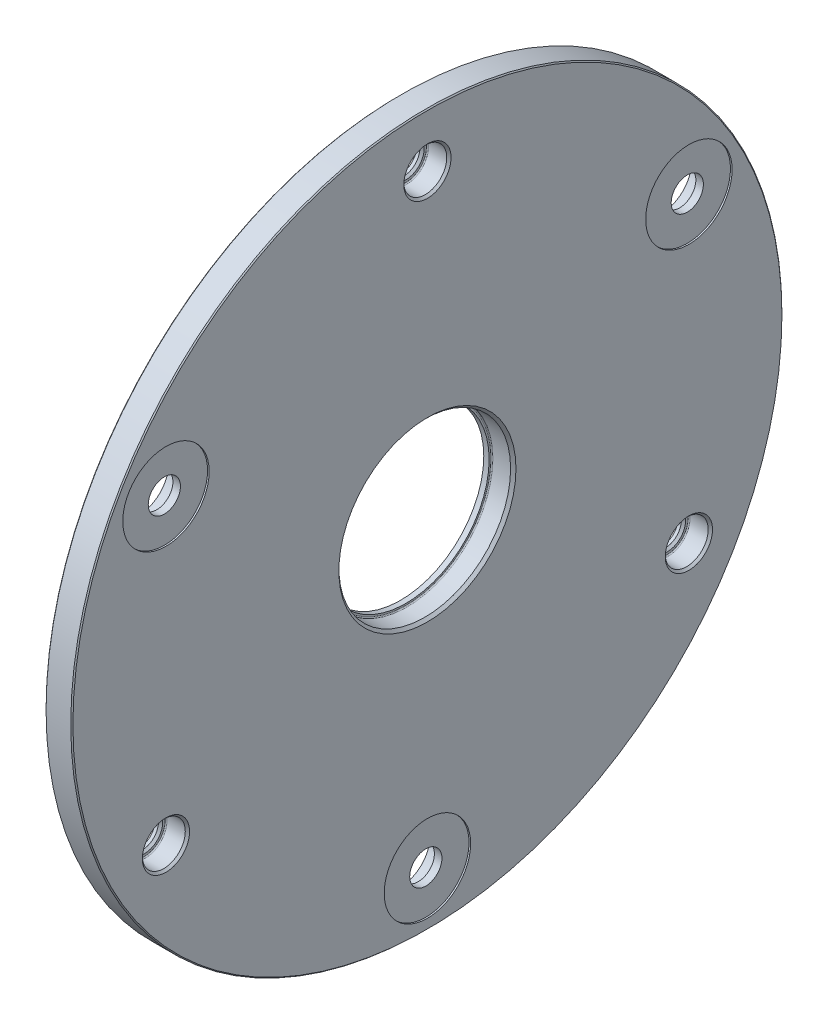
from build123d import *

# Parameters (mm, degrees)
SKETCH2_R                       = 66.25
SKETCH2_R_2                     = 16
BOSS_EXTRUDE1_DEPTH             = 5
SKETCH4_R                       = 3
CUT_EXTRUDE1_DEPTH              = 5
SKETCH4_3_R                     = 4
SKETCH4_3_R_2                   = 3
CUT_EXTRUDE2_DEPTH              = 4
CHAMFER1_SIZE                   = 0.4
FILLET3_R                       = 0.2
SKETCH5_R                       = 8.05
CUT_EXTRUDE3_DEPTH              = 0.3
CBORE_FOR_M6_SBHCS1_D           = 6
CBORE_FOR_M6_SBHCS1_CBORE_D     = 11
CBORE_FOR_M6_SBHCS1_CBORE_DEPTH = 3.3
CIRPATTERN1_COUNT               = 3
CHAMFER1_OF_CIRPATTERN1_SIZE    = 0.4
FILLET3_OF_CIRPATTERN1_R        = 0.2
BOSS_EXTRUDE2_START             = -5
SKETCH8_R                       = 16
SKETCH8_R_2                     = 15.5
BOSS_EXTRUDE2_DEPTH             = 1
FILLET2_R                       = 0.2
CHAMFER2_SIZE                   = 0.5
CHAMFER3_SIZE                   = 0.2


with BuildPart() as part:
    # Sketch2 → Boss-Extrude1 (new body)
    with BuildSketch(Plane(origin=(0, 0, 0), x_dir=(0, 0, -1), z_dir=(1, 0, 0))):
        Circle(SKETCH2_R)
        Circle(SKETCH2_R_2, mode=Mode.SUBTRACT)
    extrude(amount=-BOSS_EXTRUDE1_DEPTH)

    # Sketch4 → Cut-Extrude1 (cut)
    with BuildSketch(Plane(origin=(0, 0, 0), x_dir=(0, 0, -1), z_dir=(1, 0, 0))):
        with Locations((0, 56.25)):
            Circle(SKETCH4_R)
    cut_extrude1 = extrude(amount=-CUT_EXTRUDE1_DEPTH, mode=Mode.SUBTRACT)

    # Sketch4_3 → Cut-Extrude2 (cut)
    with BuildSketch(Plane(origin=(0, 0, 0), x_dir=(0, 0, -1), z_dir=(1, 0, 0))):
        with Locations((0, 56.25)):
            Circle(SKETCH4_3_R)
        with Locations((0, 56.25)):
            Circle(SKETCH4_3_R_2, mode=Mode.SUBTRACT)
    cut_extrude2 = extrude(amount=-CUT_EXTRUDE2_DEPTH, mode=Mode.SUBTRACT)

    # Chamfer1
    chamfer1_edges = [part.edges().sort_by_distance(p)[0] for p in [
        (0, 56.25, 4),
        (-4, 56.25, 3),
    ]]
    chamfer(chamfer1_edges, length=CHAMFER1_SIZE)

    # Fillet3
    fillet3_edges = [part.edges().sort_by_distance(p)[0] for p in [
        (-4, 56.25, 4),
    ]]
    fillet(fillet3_edges, radius=FILLET3_R)

    # Sketch5 → Cut-Extrude3 (cut)
    with BuildSketch(Plane(origin=(0, 0, 0), x_dir=(0, 0, -1), z_dir=(1, 0, 0))):
        with Locations((48.713928963, 28.125)):
            Circle(SKETCH5_R)
    cut_extrude3 = extrude(amount=-CUT_EXTRUDE3_DEPTH, mode=Mode.SUBTRACT)

    # CBORE for M6 SBHCS1 (through all)
    with Locations(Plane.ZY.offset(5)):
        with Locations((-48.713928963, 28.125)):
            cbore_for_m6_sbhcs1 = CounterBoreHole(CBORE_FOR_M6_SBHCS1_D / 2, CBORE_FOR_M6_SBHCS1_CBORE_D / 2, CBORE_FOR_M6_SBHCS1_CBORE_DEPTH)

    # CirPattern1: Cut-Extrude1, Cut-Extrude2, Cut-Extrude3, CBORE for M6 SBHCS1 ×3 about axis
    cirpattern1_axis = Axis((0, 0, 0), (1, 0, 0))
    for i in range(1, CIRPATTERN1_COUNT):
        add(cut_extrude1.rotate(cirpattern1_axis, i * 360 / CIRPATTERN1_COUNT), mode=Mode.SUBTRACT)
        add(cut_extrude2.rotate(cirpattern1_axis, i * 360 / CIRPATTERN1_COUNT), mode=Mode.SUBTRACT)
        add(cut_extrude3.rotate(cirpattern1_axis, i * 360 / CIRPATTERN1_COUNT), mode=Mode.SUBTRACT)
        add(cbore_for_m6_sbhcs1.rotate(cirpattern1_axis, i * 360 / CIRPATTERN1_COUNT), mode=Mode.SUBTRACT)

    # Chamfer1 of CirPattern1
    chamfer1_of_cirpattern1_edges = [part.edges().sort_by_distance(p)[0] for p in [
        (0, -31.589101615, 46.713928963),
        (-4, -30.723076211, 47.213928963),
        (0, -24.660898385, -50.713928963),
        (-4, -25.526923789, -50.213928963),
    ]]
    chamfer(chamfer1_of_cirpattern1_edges, length=CHAMFER1_OF_CIRPATTERN1_SIZE)

    # Fillet3 of CirPattern1
    fillet3_of_cirpattern1_edges = [part.edges().sort_by_distance(p)[0] for p in [
        (-4, -31.589101615, 46.713928963),
        (-4, -24.660898385, -50.713928963),
    ]]
    fillet(fillet3_of_cirpattern1_edges, radius=FILLET3_OF_CIRPATTERN1_R)

    # Sketch8 → Boss-Extrude2 (add)
    with BuildSketch(Plane(origin=(0, 0, 0), x_dir=(0, 0, -1), z_dir=(1, 0, 0)).offset(BOSS_EXTRUDE2_START)):
        Circle(SKETCH8_R)
        Circle(SKETCH8_R_2, mode=Mode.SUBTRACT)
    extrude(amount=BOSS_EXTRUDE2_DEPTH)

    # Fillet2
    fillet2_edges = [part.edges().sort_by_distance(p)[0] for p in [
        (-4, 0, 16),
    ]]
    fillet(fillet2_edges, radius=FILLET2_R)

    # Chamfer2
    chamfer2_edges = [part.edges().sort_by_distance(p)[0] for p in [
        (0, 0, 16),
    ]]
    chamfer(chamfer2_edges, length=CHAMFER2_SIZE)

    # Chamfer3
    chamfer3_edges = [part.edges().sort_by_distance(p)[0] for p in [
        (0, 0, 66.25),
        (-5, 0, 66.25),
    ]]
    chamfer(chamfer3_edges, length=CHAMFER3_SIZE)


solid = part.part
